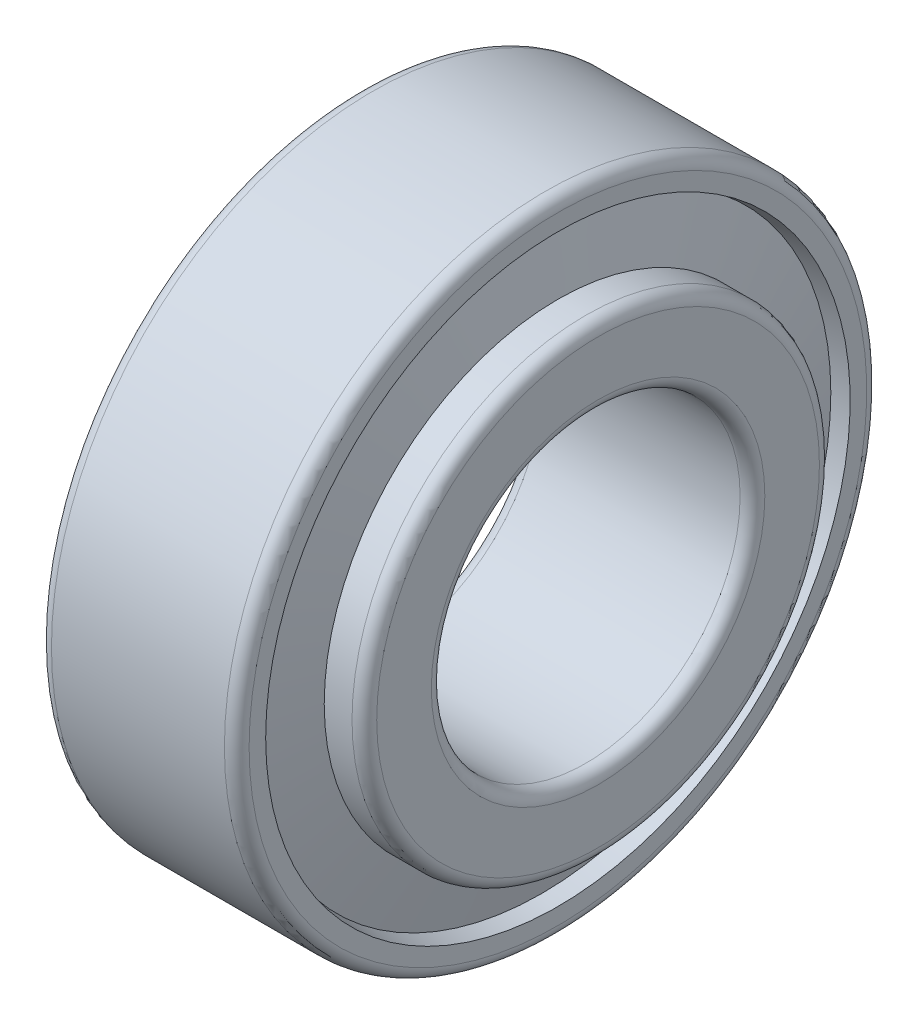
from build123d import *


with BuildPart() as part:
    # Эскиз1 → Повернуть1 (revolve)
    with BuildSketch(Plane.XY):
        with BuildLine():
            Line((2.853353658, 21.199250144), (0, 20.6655))
            Line((0, 20.6655), (0, 25))
            ThreePointArc((0, 25), (0.292893219, 25.707106781), (1, 26))
            Line((1, 26), (15, 26))
            ThreePointArc((15, 26), (15.707106781, 25.707106781), (16, 25))
            Line((16, 25), (16, 23.658470141))
            Line((16, 23.658470141), (14.68134279, 23.411801288))
            Line((14.68134279, 23.411801288), (16, 17.919198712))
            Line((16, 17.919198712), (16, 18.919198712))
            Line((16, 18.919198712), (18.25, 18.919198712))
            ThreePointArc((18.25, 18.919198712), (18.957106781, 18.626305494), (19.25, 17.919198712))
            Line((19.25, 17.919198712), (19.25, 13.5))
            ThreePointArc((19.25, 13.5), (18.957106781, 12.792893219), (18.25, 12.5))
            Line((18.25, 12.5), (2.25, 12.5))
            ThreePointArc((2.25, 12.5), (1.542893219, 12.792893219), (1.25, 13.5))
            Line((1.25, 13.5), (1.25, 14.52080152))
            Line((1.25, 14.52080152), (4.456707316, 14.52080152))
            Line((4.456707316, 14.52080152), (2.853353658, 21.199250144))
        make_face()
    revolve(axis=Axis((-882.527700014, 0, 0), (1, 0, 0)))


solid = part.part
